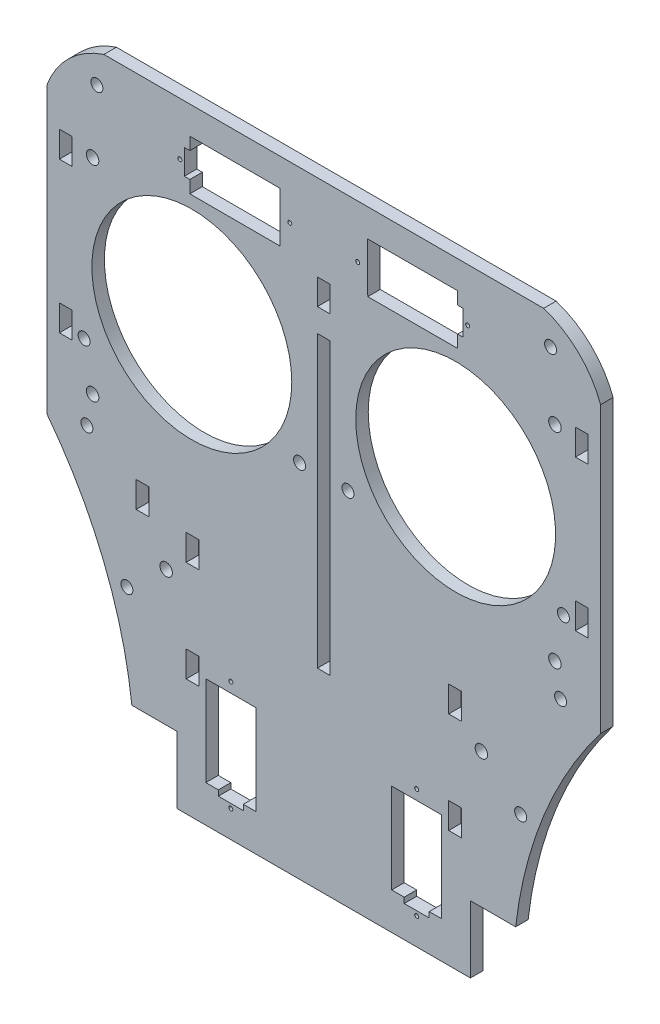
from build123d import *

# Parameters (mm, degrees)
SKETCH1_W                            = 140.716
SKETCH1_H                            = 139.7
MAIN_BODY_DEPTH                      = 3.175
SKETCH2_R                            = 25.4
SKETCH2_R_2                          = 1.524
SKETCH2_R_3                          = 0.508
CUTS_FOR_EYES_AND_MOTORS_DEPTH       = 4.175
SKETCH3_W                            = 3.2258
SKETCH3_H                            = 6.604
CUT_FOR_ASSEMBLY_SLOTS_DEPTH         = 4.175
SKETCH4_W                            = 3.2258
SKETCH4_H                            = 73.66
SKETCH4_H_2                          = 6.5278
CUT_FOR_NOSE_DEPTH                   = 4.175
SKETCH9_W                            = 3.2258
SKETCH9_H                            = 6.604
SLOT_FOR_MANDIBLE_DEPTH              = 4.175
CUT_FOR_ROUNDED_FACE_FEATURES_DEPTH  = 4.175
SKETCH12_R                           = 1.524
HOLES_FOR_SPACERS_DEPTH              = 4.175
SKETCH13_R                           = 1.5875
CUT_FOR_FACE_PLATE_MOUNT_SCREW_DEPTH = 4.175
SKETCH15_W                           = 37.279626203
SKETCH15_H                           = 16.998263706
EXTENSION_FOR_LIP_MOTOR_DEPTH        = 3.175
SKETCH16_R                           = 0.508
CUT_FOR_LIP_MOTOR_DEPTH              = 4.175
SKETCH18_R                           = 1.5875
CUT_FOR_BRACKET_SCREW_DEPTH          = 4.175
SKETCH19_W                           = 3.2512
SKETCH19_H                           = 6.604
CUT_FOR_GEAR_TAB_DEPTH               = 4.175


with BuildPart() as part:
    # Sketch1 → main body (new body)
    with BuildSketch(Plane.XY):
        with Locations((0, -69.85)):
            Rectangle(SKETCH1_W, SKETCH1_H)
    extrude(amount=MAIN_BODY_DEPTH)

    # Sketch2 → cuts for eyes and motors (cut, through all)
    with BuildSketch(Plane.XY.offset(3.175)):
        with Locations((-33.528, -48.26)):
            Circle(SKETCH2_R)
        with Locations((-6.1468, -65.024)):
            Circle(SKETCH2_R_2)
        with Locations((-60.9092, -65.024)):
            Circle(SKETCH2_R_2)
        with Locations((-36.575996282, -13.412523563)):
            Circle(SKETCH2_R_3)
        with Locations((-8.636008311, -13.438449703)):
            Circle(SKETCH2_R_3)
        Polygon((-11.170114913, -7.086095515), (-34.030105071, -7.064883219), (-34.033051223, -10.239881852), (-35.430050622, -10.238585545), (-35.435942926, -16.588582811), (-34.038943528, -16.589879118), (-34.04188968, -19.764877751), (-11.181899522, -19.786090048), align=None)
    cuts_for_eyes_and_motors = extrude(amount=-CUTS_FOR_EYES_AND_MOTORS_DEPTH, mode=Mode.SUBTRACT)

    # Sketch3 → cut for assembly slots (cut, through all)
    with BuildSketch(Plane.XY.offset(3.175)):
        with Locations((-65.5701, -63.627)):
            Rectangle(SKETCH3_W, SKETCH3_H)
        with Locations((-65.5701, -25.4)):
            Rectangle(SKETCH3_W, SKETCH3_H)
    cut_for_assembly_slots = extrude(amount=-CUT_FOR_ASSEMBLY_SLOTS_DEPTH, mode=Mode.SUBTRACT)

    # Sketch4 → cut for nose (cut, through all)
    with BuildSketch(Plane.XY.offset(3.175)):
        with Locations((0, -71.12)):
            Rectangle(SKETCH4_W, SKETCH4_H)
        with Locations((0, -25.1079)):
            Rectangle(SKETCH4_W, SKETCH4_H_2)
    extrude(amount=-CUT_FOR_NOSE_DEPTH, mode=Mode.SUBTRACT)

    # Sketch9 → slot for mandible (cut, through all)
    with BuildSketch(Plane.XY.offset(3.175)):
        with Locations((-33.3629, -98.044)):
            Rectangle(SKETCH9_W, SKETCH9_H)
        with Locations((-33.3629, -123.698)):
            Rectangle(SKETCH9_W, SKETCH9_H)
    slot_for_mandible = extrude(amount=-SLOT_FOR_MANDIBLE_DEPTH, mode=Mode.SUBTRACT)

    # mirror of assembly slots: cut for assembly slots across plane
    add(cut_for_assembly_slots.mirror(Plane(origin=(0, 0, 0), x_dir=(0, 0, 1), z_dir=(1, 0, 0))), mode=Mode.SUBTRACT)

    # Mirror1: cuts for eyes and motors across plane
    add(cuts_for_eyes_and_motors.mirror(Plane(origin=(0, 0, 0), x_dir=(0, 0, 1), z_dir=(1, 0, 0))), mode=Mode.SUBTRACT)

    # Sketch11 → cut for rounded face features (cut, through all)
    with BuildSketch(Plane.XY.offset(3.175)):
        with BuildLine():
            Line((-70.358, -139.7), (-70.358, -86.36))
            ThreePointArc((-70.358, -86.36), (-55.943359781, -111.56490753), (-48.768, -139.7))
            Line((-48.768, -139.7), (-70.358, -139.7))
        make_face()
        with BuildLine():
            Line((-70.358, 0), (-70.358, -13.97))
            ThreePointArc((-70.358, -13.97), (-64.724440046, -5.321180316), (-55.88, 0))
            Line((-55.88, 0), (-70.358, 0))
        make_face()
    cut_for_rounded_face_features = extrude(amount=-CUT_FOR_ROUNDED_FACE_FEATURES_DEPTH, mode=Mode.SUBTRACT)

    # Mirror2: cut for rounded face features across plane
    add(cut_for_rounded_face_features.mirror(Plane(origin=(0, 0, 0), x_dir=(0, 0, 1), z_dir=(1, 0, 0))), mode=Mode.SUBTRACT)

    # Sketch12 → holes for spacers (cut, through all)
    with BuildSketch(Plane.XY.offset(3.175)):
        with Locations((-57.658, -7.62)):
            Circle(SKETCH12_R)
        with Locations((-60.198, -83.82)):
            Circle(SKETCH12_R)
        with Locations((-50.038, -114.3)):
            Circle(SKETCH12_R)
    holes_for_spacers = extrude(amount=-HOLES_FOR_SPACERS_DEPTH, mode=Mode.SUBTRACT)

    # Mirror3: holes for spacers across plane
    add(holes_for_spacers.mirror(Plane(origin=(0, 0, 0), x_dir=(0, 0, 1), z_dir=(1, 0, 0))), mode=Mode.SUBTRACT)

    # Mirror4: slot for mandible across plane
    add(slot_for_mandible.mirror(Plane(origin=(0, 0, 0), x_dir=(0, 0, 1), z_dir=(1, 0, 0))), mode=Mode.SUBTRACT)

    # Sketch13 → cut for face plate mount screw (cut, through all)
    with BuildSketch(Plane.XY.offset(3.175)):
        with Locations((58.7502, -24.13)):
            Circle(SKETCH13_R)
        with Locations((58.7502, -76.2)):
            Circle(SKETCH13_R)
    cut_for_face_plate_mount_screw = extrude(amount=-CUT_FOR_FACE_PLATE_MOUNT_SCREW_DEPTH, mode=Mode.SUBTRACT)

    # Mirror5: cut for face plate mount screw across plane
    add(cut_for_face_plate_mount_screw.mirror(Plane(origin=(0, 0, 0), x_dir=(0, 0, 1), z_dir=(1, 0, 0))), mode=Mode.SUBTRACT)

    # Sketch15 → extension for lip motor (add)
    with BuildSketch(Plane.XY.offset(3.175)):
        with Locations((-18.639813101, -148.199131853)):
            Rectangle(SKETCH15_W, SKETCH15_H)
    extension_for_lip_motor = extrude(amount=-EXTENSION_FOR_LIP_MOTOR_DEPTH)

    # mirror of extension for lip motor: extension for lip motor across plane
    add(extension_for_lip_motor.mirror(Plane(origin=(0, 0, 0), x_dir=(0, 0, 1), z_dir=(1, 0, 0))))

    # Sketch16 → cut for lip motor (cut, through all)
    with BuildSketch(Plane.XY.offset(3.175)):
        with Locations((-23.622, -149.86)):
            Circle(SKETCH16_R)
        with Locations((-23.622, -121.92)):
            Circle(SKETCH16_R)
        Polygon((-17.272, -124.46), (-29.972, -124.46), (-29.972, -147.32), (-26.797, -147.32), (-26.797, -148.717), (-20.447, -148.717), (-20.447, -147.32), (-17.272, -147.32), align=None)
    cut_for_lip_motor = extrude(amount=-CUT_FOR_LIP_MOTOR_DEPTH, mode=Mode.SUBTRACT)

    # mirror of lip motor: cut for lip motor across plane
    add(cut_for_lip_motor.mirror(Plane(origin=(0, 0, 0), x_dir=(0, 0, 1), z_dir=(1, 0, 0))), mode=Mode.SUBTRACT)

    # Sketch18 → cut for bracket screw (cut, through all)
    with BuildSketch(Plane.XY.offset(3.175)):
        with Locations((-40.0558, -105.41)):
            Circle(SKETCH18_R)
    cut_for_bracket_screw = extrude(amount=-CUT_FOR_BRACKET_SCREW_DEPTH, mode=Mode.SUBTRACT)

    # mirror of bracket screw: cut for bracket screw across plane
    add(cut_for_bracket_screw.mirror(Plane(origin=(0, 0, 0), x_dir=(0, 0, 1), z_dir=(1, 0, 0))), mode=Mode.SUBTRACT)

    # Sketch19 → cut for gear tab (cut, through all)
    with BuildSketch(Plane.XY.offset(3.175)):
        with Locations((-46.050399644, -92.742342074)):
            Rectangle(SKETCH19_W, SKETCH19_H)
    extrude(amount=-CUT_FOR_GEAR_TAB_DEPTH, mode=Mode.SUBTRACT)


solid = part.part
